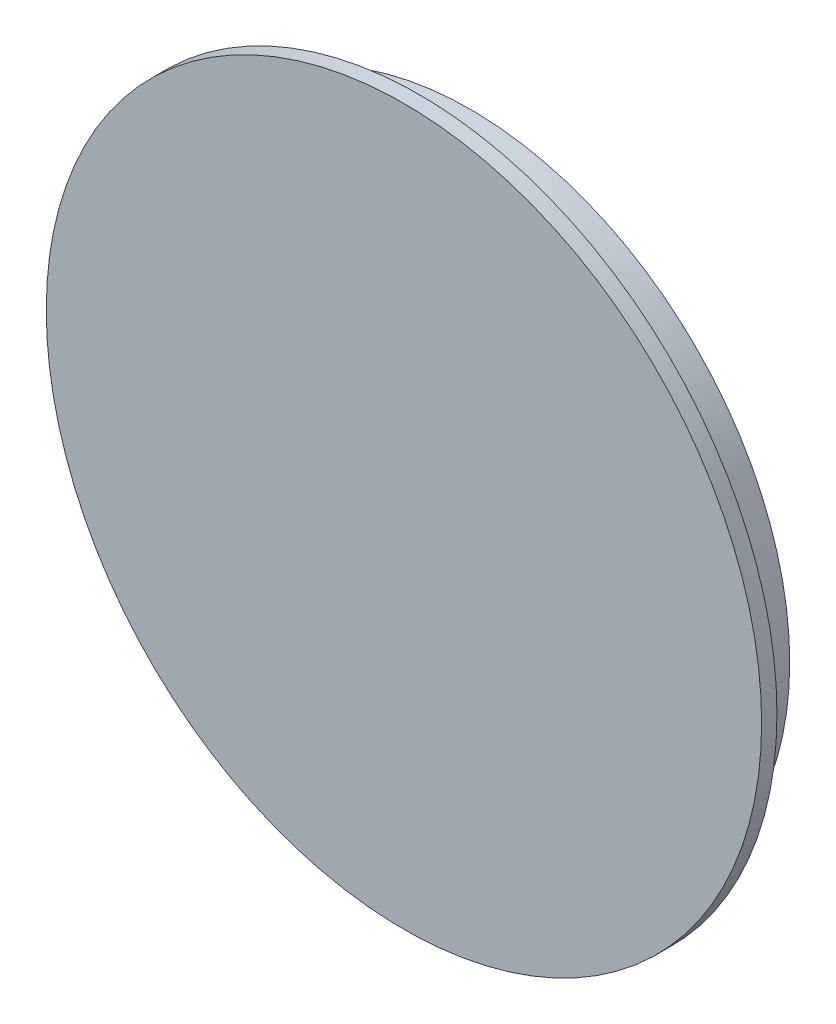
from build123d import *


with BuildPart() as part:
    # Sketch2 → Revolve1 (revolve)
    with BuildSketch(Plane(origin=(0, 0, 0), x_dir=(1, 0, 0), z_dir=(0, 1, 0))):
        Polygon((-73.025, 16.51), (-69.85, 16.51), (-69.85, 3.81), (0, 3.81), (0, 0), (-88.9, 0), (-88.9, 3.81), (-79.375, 3.81), (-79.375, 16.51), (-76.2, 16.51), (-76.2, 6.35), (-73.025, 6.35), align=None)
    revolve(axis=Axis((0, 0, 0), (0, 0, -1)))


solid = part.part
